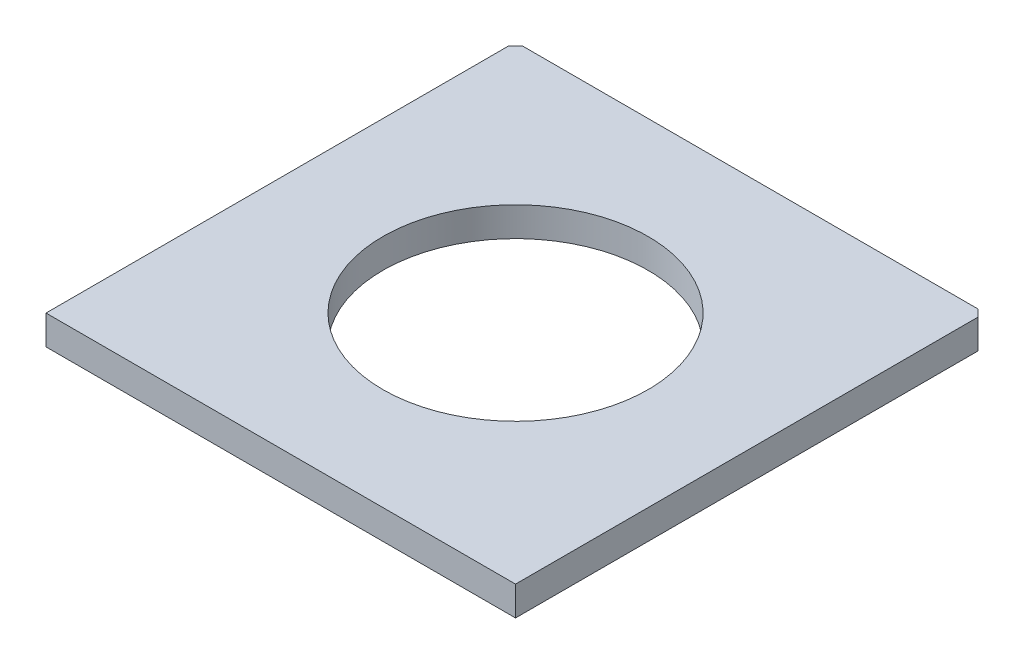
from build123d import *

# Parameters (mm, degrees)
SKETCH1_W           = 50.8
SKETCH1_H           = 50.8
BOSS_EXTRUDE1_DEPTH = 3.175
SKETCH2_R           = 14.35
CUT_EXTRUDE1_DEPTH  = 3.175
CUT_EXTRUDE2_DEPTH  = 3.175


with BuildPart() as part:
    # Sketch1 → Boss-Extrude1 (new body)
    with BuildSketch(Plane(origin=(0, 0, 0), x_dir=(1, 0, 0), z_dir=(0, 1, 0))):
        Rectangle(SKETCH1_W, SKETCH1_H)
    extrude(amount=BOSS_EXTRUDE1_DEPTH)

    # Sketch2 → Cut-Extrude1 (cut)
    with BuildSketch(Plane(origin=(0, 3.175, 0), x_dir=(1, 0, 0), z_dir=(0, 1, 0))):
        Circle(SKETCH2_R)
    extrude(amount=-CUT_EXTRUDE1_DEPTH, mode=Mode.SUBTRACT)

    # Sketch3 → Cut-Extrude2 (cut)
    with BuildSketch(Plane(origin=(0, 3.175, 0), x_dir=(1, 0, 0), z_dir=(0, 1, 0))):
        Polygon((-25.4, 25.4), (-24.638, 25.4), (-25.4, 24.638), align=None)
        Polygon((25.4, 25.4), (25.4, 24.638), (24.638, 25.4), align=None)
    extrude(amount=-CUT_EXTRUDE2_DEPTH, mode=Mode.SUBTRACT)


solid = part.part
